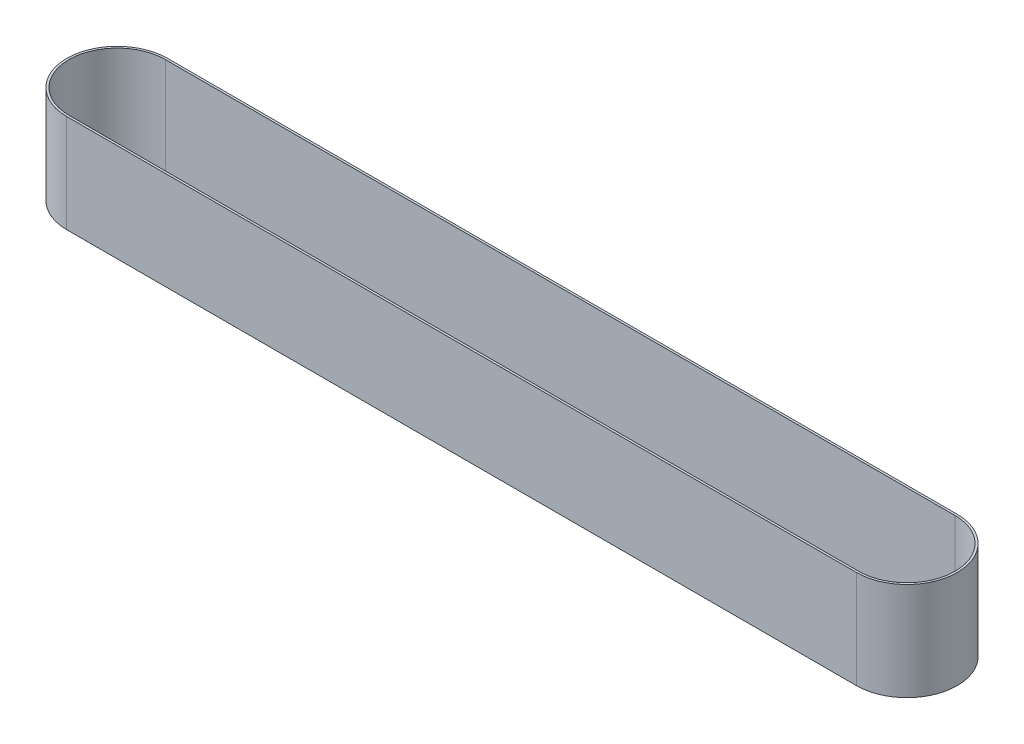
from build123d import *

# Parameters (mm, degrees)
BOSS_EXTRUDE1_DEPTH = 45.72


with BuildPart() as part:
    # Sketch1 → Boss-Extrude1 (new body)
    with BuildSketch(Plane(origin=(0, 0, 0), x_dir=(1, 0, 0), z_dir=(0, 1, 0))):
        with BuildLine():
            Line((0, 23.5), (368.3, 23.5))
            ThreePointArc((368.3, 23.5), (391.8, 0), (368.3, -23.5))
            Line((368.3, -23.5), (0, -23.5))
            ThreePointArc((0, -23.5), (-23.5, 0), (0, 23.5))
        make_face()
        with BuildLine():
            Line((0, 22.5), (368.3, 22.5))
            ThreePointArc((368.3, 22.5), (390.8, 0), (368.3, -22.5))
            Line((368.3, -22.5), (0, -22.5))
            ThreePointArc((0, -22.5), (-22.5, 0), (0, 22.5))
        make_face(mode=Mode.SUBTRACT)
    extrude(amount=BOSS_EXTRUDE1_DEPTH)


solid = part.part
